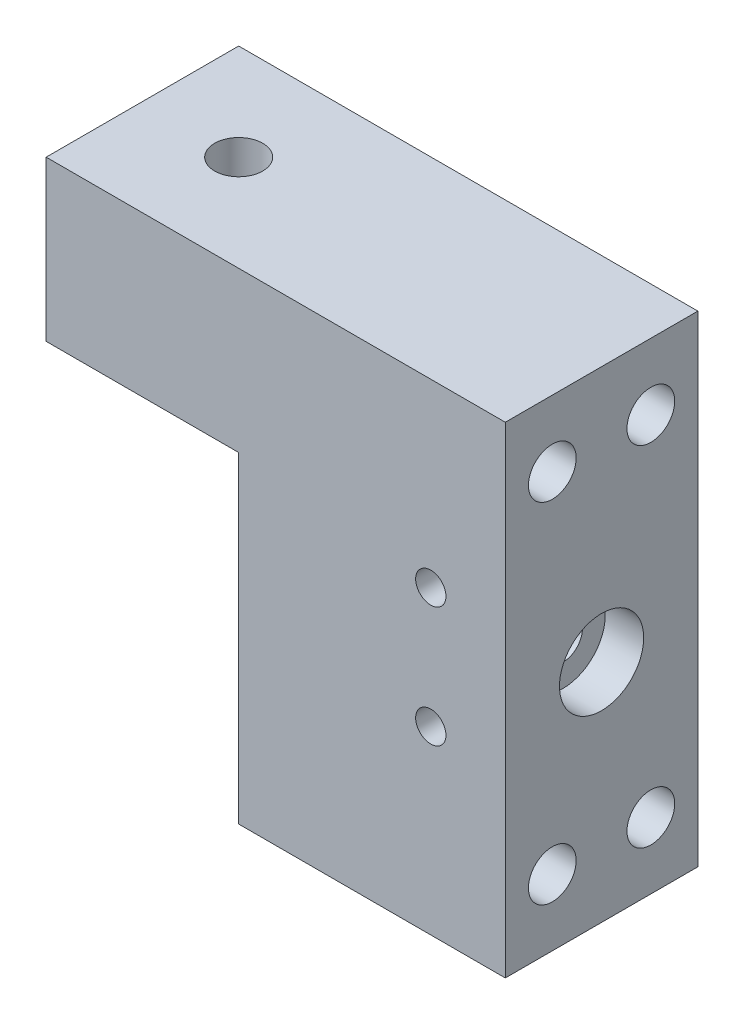
from build123d import *

# Parameters (mm, degrees)
SKETCH2_W                                           = 25.4
SKETCH2_H                                           = 63.5
BOSS_EXTRUDE1_DEPTH                                 = 35.17596
SKETCH3_W                                           = 25.4
SKETCH3_H                                           = 21.05
BOSS_EXTRUDE2_DEPTH                                 = 25.4
F_1_4_0_25_DIAMETER_HOLE1_D                         = 6.35
F_1_0MM_DOWEL_HOLE1_D                               = 6.3
F_1_0MM_DOWEL_HOLE1_DEPTH                           = 8.9916
F_1_0MM_DOWEL_HOLE1_TIP                             = 1.89271095
F_4_0MM_DOWEL_HOLE1_D                               = 4
F_4_0MM_DOWEL_HOLE1_DEPTH                           = 15.24
F_4_0MM_DOWEL_HOLE1_TIP                             = 1.201721238
CBORE_FOR_10_BINDING_HEAD_MACHINE_SCREW_D           = 5.1054
CBORE_FOR_10_BINDING_HEAD_MACHINE_SCREW_DEPTH       = 35.17596
CBORE_FOR_10_BINDING_HEAD_MACHINE_SCREW_CBORE_D     = 11.1125
CBORE_FOR_10_BINDING_HEAD_MACHINE_SCREW_CBORE_DEPTH = 5.08


with BuildPart() as part:
    # Sketch2 → Boss-Extrude1 (new body)
    with BuildSketch(Plane(origin=(0, 0, 0), x_dir=(0, 0, -1), z_dir=(1, 0, 0))):
        with Locations((-225.049350785, -379.861725806)):
            Rectangle(SKETCH2_W, SKETCH2_H)
    extrude(amount=-BOSS_EXTRUDE1_DEPTH)

    # Sketch3 → Boss-Extrude2 (add)
    with BuildSketch(Plane.ZY.offset(35.17596)):
        with Locations((225.049350785, -358.636725806)):
            Rectangle(SKETCH3_W, SKETCH3_H)
    extrude(amount=BOSS_EXTRUDE2_DEPTH)

    # 1/4 (0.25) Diameter Hole1 (through all)
    with Locations(Plane(origin=(0, -348.111725806, 0), x_dir=(1, 0, 0), z_dir=(0, 1, 0))):
        with Locations((-47.87596, -225.049350785)):
            Hole(F_1_4_0_25_DIAMETER_HOLE1_D / 2)

    # Ø1.0mm Dowel Hole1
    with Locations(Plane(origin=(0, 0, 0), x_dir=(0, 0, -1), z_dir=(1, 0, 0))):
        with Locations((-231.549350785, -356.861725806), (-218.549350785, -356.861725806), (-231.549350785, -402.861725805), (-218.549350785, -402.861725805)):
            Hole(F_1_0MM_DOWEL_HOLE1_D / 2, depth=F_1_0MM_DOWEL_HOLE1_DEPTH)
            with Locations((0, 0, -(F_1_0MM_DOWEL_HOLE1_DEPTH + F_1_0MM_DOWEL_HOLE1_TIP / 2))):  # 118° drill point
                Cone(0, F_1_0MM_DOWEL_HOLE1_D / 2, F_1_0MM_DOWEL_HOLE1_TIP, mode=Mode.SUBTRACT)

    # Ø4.0mm Dowel Hole1
    with Locations(Plane(origin=(0, 0, 237.749350785), x_dir=(-1, 0, 0), z_dir=(0, 0, 1))):
        with Locations((9.83125001, 371.924225806), (9.83125001, 387.799225806)):
            Hole(F_4_0MM_DOWEL_HOLE1_D / 2, depth=F_4_0MM_DOWEL_HOLE1_DEPTH)
            with Locations((0, 0, -(F_4_0MM_DOWEL_HOLE1_DEPTH + F_4_0MM_DOWEL_HOLE1_TIP / 2))):  # 118° drill point
                Cone(0, F_4_0MM_DOWEL_HOLE1_D / 2, F_4_0MM_DOWEL_HOLE1_TIP, mode=Mode.SUBTRACT)

    # CBORE for #10 Binding Head Machine Screw1
    with Locations(Plane(origin=(0, 0, 0), x_dir=(0, 0, -1), z_dir=(1, 0, 0))):
        with Locations((-225.049350785, -381.861725806)):
            CounterBoreHole(CBORE_FOR_10_BINDING_HEAD_MACHINE_SCREW_D / 2, CBORE_FOR_10_BINDING_HEAD_MACHINE_SCREW_CBORE_D / 2, CBORE_FOR_10_BINDING_HEAD_MACHINE_SCREW_CBORE_DEPTH, depth=CBORE_FOR_10_BINDING_HEAD_MACHINE_SCREW_DEPTH)


solid = part.part
